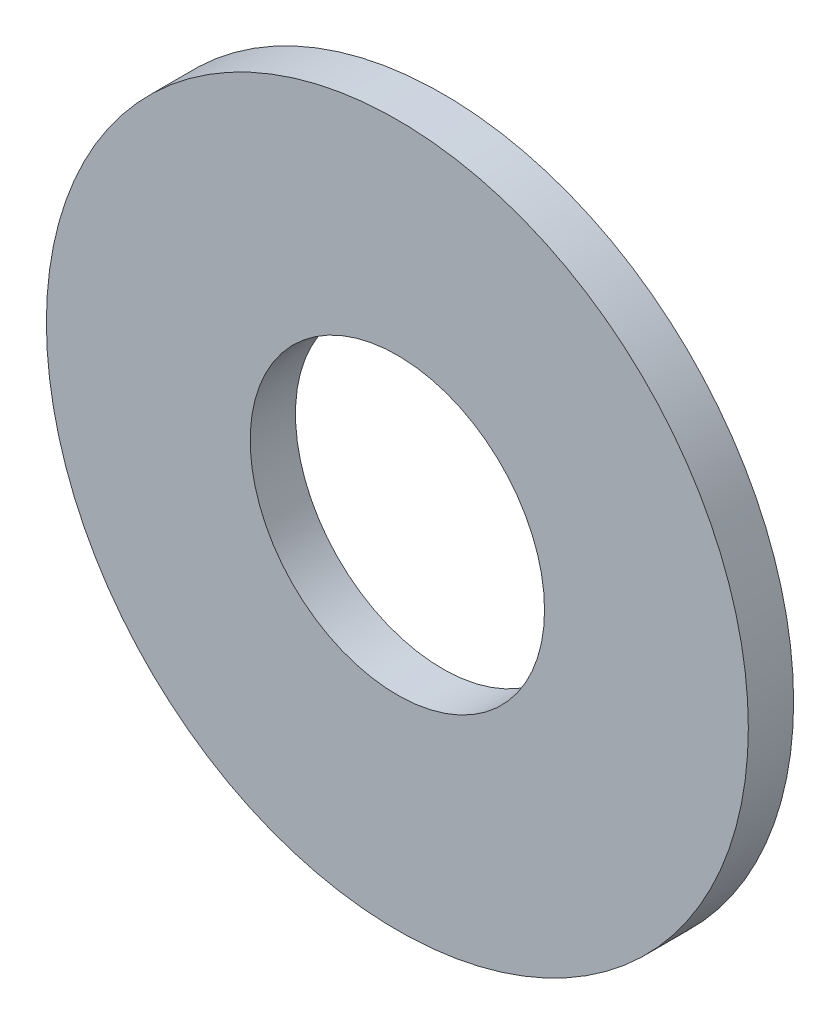
from build123d import *

# Parameters (mm, degrees)
SKETCH1_R           = 49.2125
SKETCH1_R_2         = 20.6375
BOSS_EXTRUDE1_DEPTH = 6.35


with BuildPart() as part:
    # Sketch1 → Boss-Extrude1 (new body)
    with BuildSketch(Plane.XY):
        Circle(SKETCH1_R)
        Circle(SKETCH1_R_2, mode=Mode.SUBTRACT)
    extrude(amount=BOSS_EXTRUDE1_DEPTH)


solid = part.part
